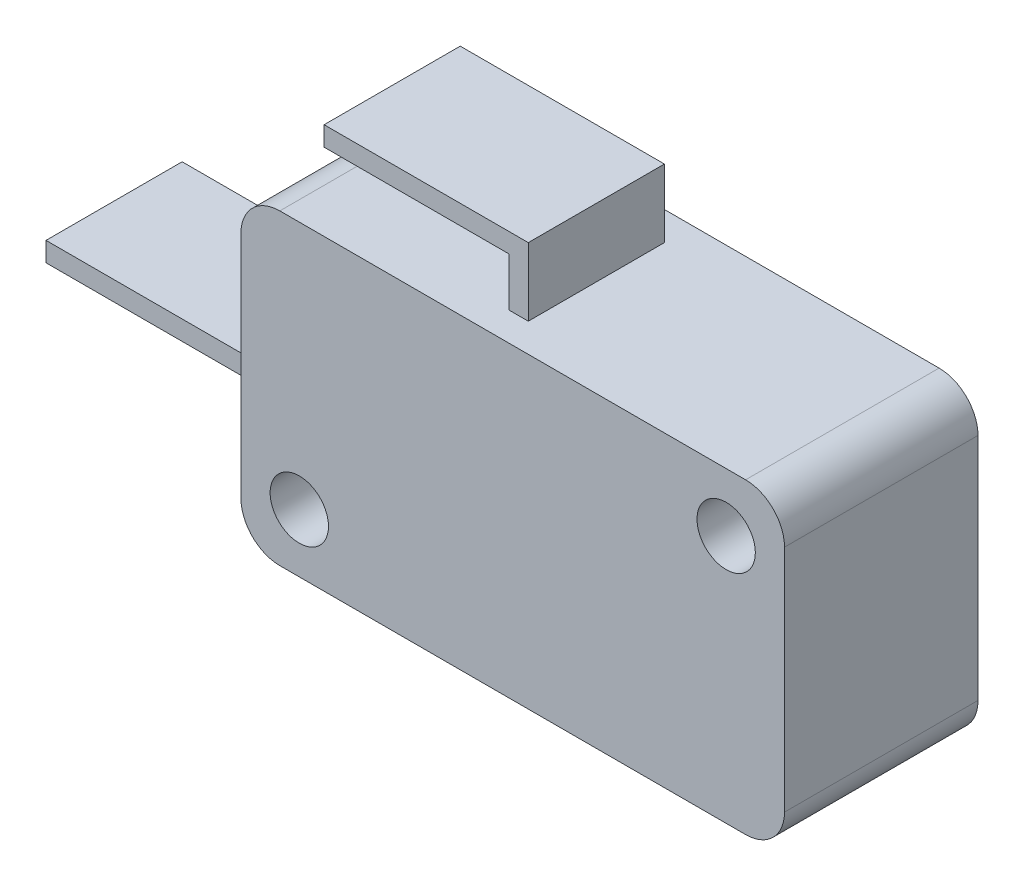
from build123d import *

# Parameters (mm, degrees)
SKETCH1_W      = 27.95
SKETCH1_H      = 15.8
EXTRUDE1_DEPTH = 9.95
SKETCH2_R      = 1.5
EXTRUDE2_DEPTH = 10.95
FILLET1_R      = 2
SKETCH3_W      = 7
SKETCH3_H      = 1
EXTRUDE3_DEPTH = 11.5
SKETCH4_W      = 1
SKETCH4_H      = 7
EXTRUDE4_DEPTH = 3.5
SKETCH5_W      = 7
SKETCH5_H      = 1
EXTRUDE5_DEPTH = 9.5
SKETCH6_W      = 2.6
SKETCH6_H      = 4
EXTRUDE6_DEPTH = 3
SKETCH7_W      = 1
SKETCH7_H      = 3.836260464
EXTRUDE7_DEPTH = 3
SKETCH8_R      = 0.25
EXTRUDE8_DEPTH = 1


with BuildPart() as part:
    # Sketch1 → Extrude1 (new body)
    with BuildSketch(Plane.XY):
        Rectangle(SKETCH1_W, SKETCH1_H)
    extrude(amount=EXTRUDE1_DEPTH)

    # Sketch2 → Extrude2 (cut, through all)
    with BuildSketch(Plane.XY.offset(9.95)):
        with Locations((10.975, 4.9)):
            Circle(SKETCH2_R)
        with Locations((-10.975, -4.9)):
            Circle(SKETCH2_R)
    extrude(amount=-EXTRUDE2_DEPTH, mode=Mode.SUBTRACT)

    # Fillet1
    fillet1_edges = [part.edges().sort_by_distance(p)[0] for p in [
        (-13.975, 7.9, 4.975),
        (13.975, 7.9, 4.975),
        (13.975, -7.9, 4.975),
        (-13.975, -7.9, 4.975),
    ]]
    fillet(fillet1_edges, radius=FILLET1_R)

    # Sketch3 → Extrude3 (add)
    with BuildSketch(Plane.ZY.offset(13.975)):
        with Locations((4.975, -1.4)):
            Rectangle(SKETCH3_W, SKETCH3_H)
    extrude(amount=EXTRUDE3_DEPTH)

    # Sketch4 → Extrude4 (add)
    with BuildSketch(Plane(origin=(0, 7.9, 0), x_dir=(-1, 0, 0), z_dir=(0, 1, 0))):
        with Locations((1.175, 4.975)):
            Rectangle(SKETCH4_W, SKETCH4_H)
    extrude(amount=EXTRUDE4_DEPTH)

    # Sketch5 → Extrude5 (add)
    with BuildSketch(Plane.ZY.offset(1.675)):
        with Locations((4.975, 10.9)):
            Rectangle(SKETCH5_W, SKETCH5_H)
    extrude(amount=EXTRUDE5_DEPTH)

    # Sketch6 → Extrude6 (cut)
    with BuildSketch(Plane.XZ.offset(7.9)):
        with Locations((8.275, 4.975)):
            Rectangle(SKETCH6_W, SKETCH6_H)
    extrude(amount=-EXTRUDE6_DEPTH, mode=Mode.SUBTRACT)

    # Sketch7 → Extrude7 (cut)
    with BuildSketch(Plane.XZ.offset(7.9)):
        with Locations((-2.025, 5.414128699)):
            Rectangle(SKETCH7_W, SKETCH7_H)
    extrude(amount=-EXTRUDE7_DEPTH, mode=Mode.SUBTRACT)

    # Sketch8 → Extrude8 (cut)
    with BuildSketch(Plane(origin=(0, 0, 7.332258931), x_dir=(-1, 0, 0), z_dir=(0, 0, -1))):
        with Locations((2.025, -5.4)):
            Circle(SKETCH8_R)
    extrude(amount=-EXTRUDE8_DEPTH, mode=Mode.SUBTRACT)


solid = part.part
